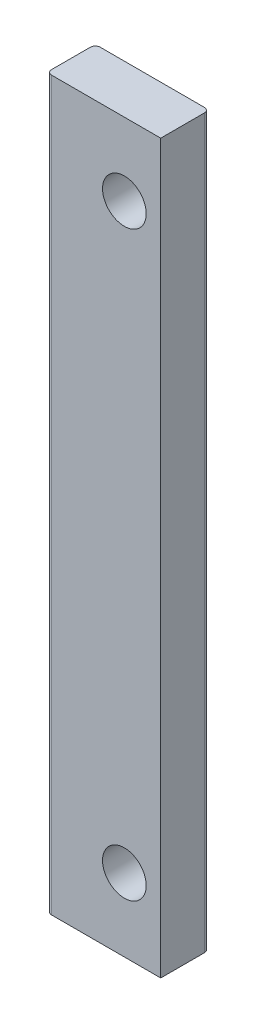
from build123d import *

# Parameters (mm, degrees)
BOSS_EXTRUDE1_DEPTH  = 150
M8_CLEARANCE_HOLE1_D = 9


with BuildPart() as part:
    # Sketch1 → Boss-Extrude1 (new body)
    with BuildSketch(Plane(origin=(0, 0, 0), x_dir=(1, 0, 0), z_dir=(0, 1, 0))):
        with BuildLine():
            Line((-10.75, -5), (11.75, -5))
            Line((11.75, -5), (11.75, 4))
            ThreePointArc((11.75, 4), (11.457106781, 4.707106781), (10.75, 5))
            Line((10.75, 5), (-10.75, 5))
            ThreePointArc((-10.75, 5), (-11.457106781, 4.707106781), (-11.75, 4))
            Line((-11.75, 4), (-11.75, -4))
            ThreePointArc((-11.75, -4), (-11.457106781, -4.707106781), (-10.75, -5))
        make_face()
    extrude(amount=BOSS_EXTRUDE1_DEPTH)

    # M8 Clearance Hole1 (through all)
    with Locations(Plane(origin=(0, 0, -5), x_dir=(-1, 0, 0), z_dir=(0, 0, -1))):
        with Locations((-4.25, 135), (-4.25, 15)):
            Hole(M8_CLEARANCE_HOLE1_D / 2)


solid = part.part
